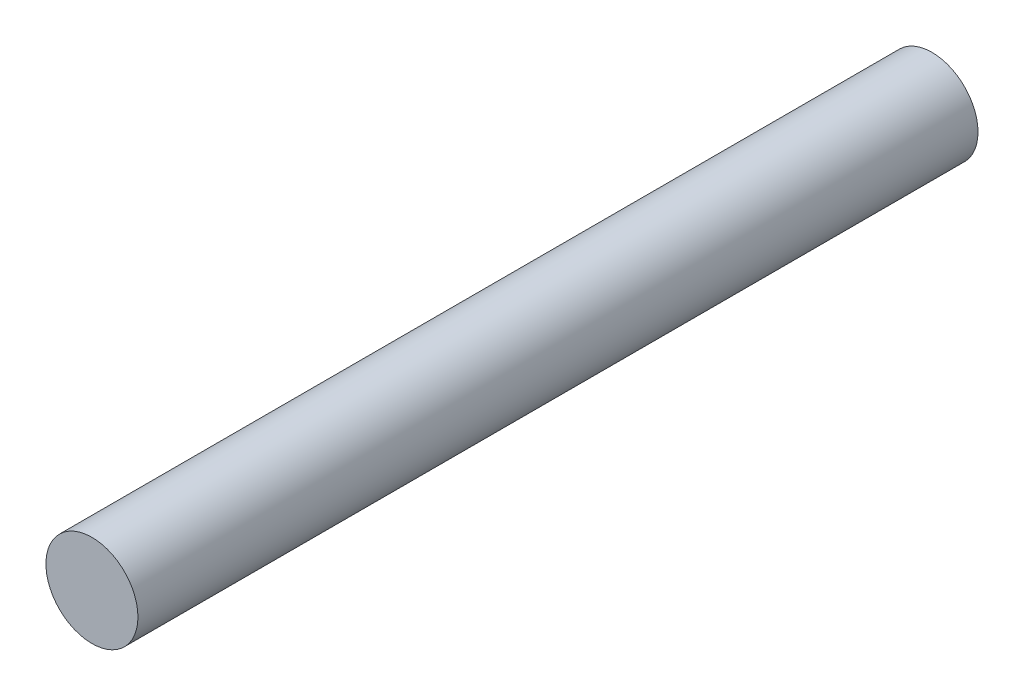
from build123d import *

# Parameters (mm, degrees)
SKETCH1_R           = 3.4925
BOSS_EXTRUDE1_DEPTH = 63.758


with BuildPart() as part:
    # Sketch1 → Boss-Extrude1 (new body)
    with BuildSketch(Plane.XY):
        Circle(SKETCH1_R)
    extrude(amount=-BOSS_EXTRUDE1_DEPTH)


solid = part.part
